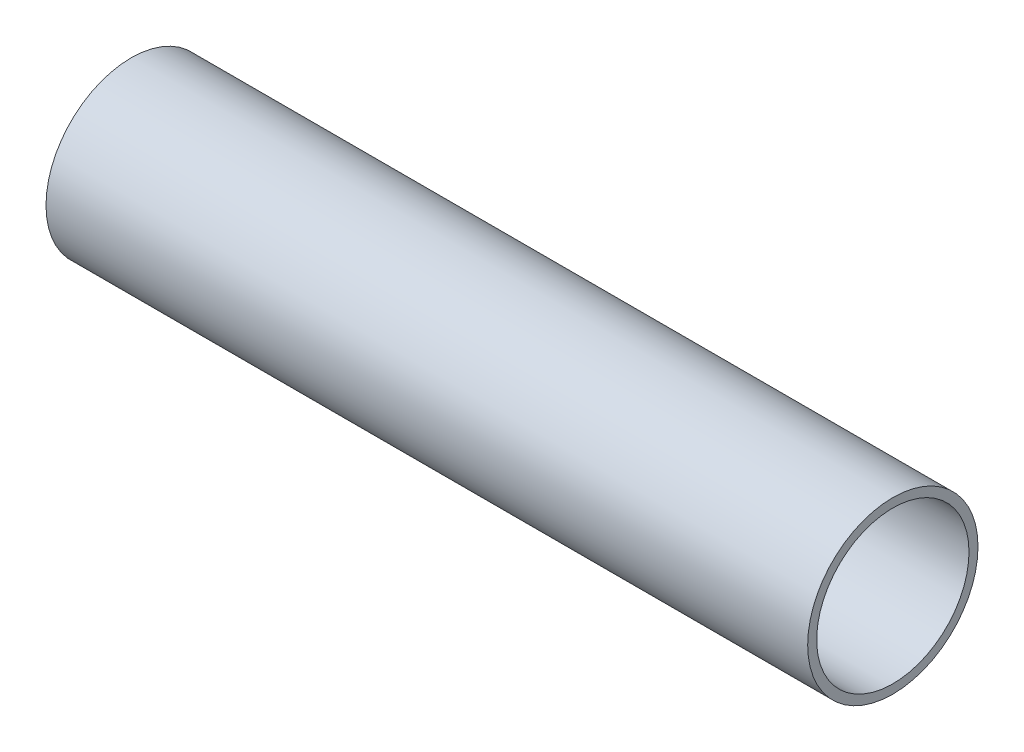
from build123d import *

# Parameters (mm, degrees)
SKETCH1_R           = 56.8
SKETCH1_R_2         = 50.8
BOSS_EXTRUDE1_DEPTH = 508


with BuildPart() as part:
    # Sketch1 → Boss-Extrude1 (new body)
    with BuildSketch(Plane(origin=(0, 0, 0), x_dir=(0, 0, -1), z_dir=(1, 0, 0))):
        Circle(SKETCH1_R)
        Circle(SKETCH1_R_2, mode=Mode.SUBTRACT)
    extrude(amount=BOSS_EXTRUDE1_DEPTH)


solid = part.part
